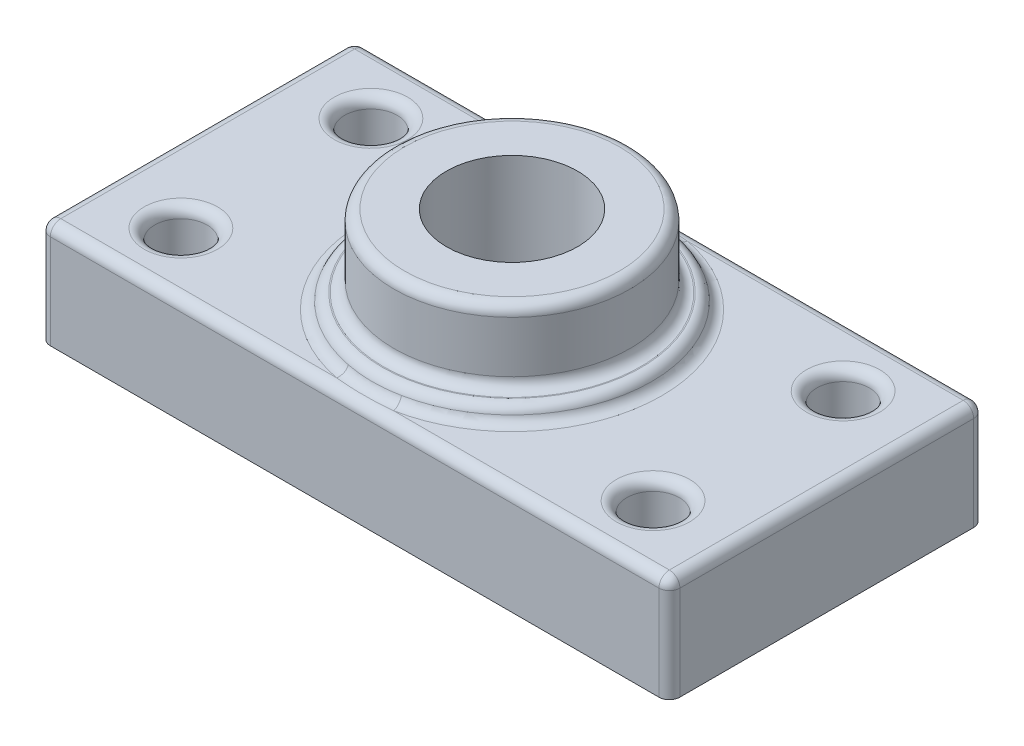
from build123d import *

# Parameters (mm, degrees)
SKETCH1_W               = 152.4
SKETCH1_H               = 76.2
SKETCH1_R               = 33.915986058
SKETCH1_R_2             = 6.35
BOSS_EXTRUDE4_DEPTH     = 25.4
SKETCH5_R               = 33.915986058
BOSS_EXTRUDE5_DEPTH     = 28.956
SKETCH6_R               = 28.575
BOSS_EXTRUDE6_DEPTH     = 46.482
SKETCH7_R               = 15.875
CUT_EXTRUDE2_DEPTH      = 51.054
CUT_EXTRUDE2_DEPTH_BACK = 0.254
SKETCH8_W               = 152.4
SKETCH8_H               = 76.2
BOSS_EXTRUDE8_DEPTH     = 2.54
FILLET1_R               = 2.54
FILLET2_R               = 2.54
FILLET3_R               = 2.54


with BuildPart() as part:
    # Sketch1 → Boss-Extrude4 (new body)
    with BuildSketch(Plane(origin=(0, 0, 0), x_dir=(1, 0, 0), z_dir=(0, 1, 0))):
        Rectangle(SKETCH1_W, SKETCH1_H)
        Circle(SKETCH1_R, mode=Mode.SUBTRACT)
        with Locations((57.15, -23.003511002)):
            Circle(SKETCH1_R_2, mode=Mode.SUBTRACT)
        with Locations((-57.15, -23.003511002)):
            Circle(SKETCH1_R_2, mode=Mode.SUBTRACT)
        with Locations((-57.15, 23.003511002)):
            Circle(SKETCH1_R_2, mode=Mode.SUBTRACT)
        with Locations((57.15, 23.003511002)):
            Circle(SKETCH1_R_2, mode=Mode.SUBTRACT)
    extrude(amount=BOSS_EXTRUDE4_DEPTH)

    # Sketch5 → Boss-Extrude5 (add)
    with BuildSketch(Plane(origin=(0, 0, 0), x_dir=(1, 0, 0), z_dir=(0, 1, 0))):
        Circle(SKETCH5_R)
    extrude(amount=BOSS_EXTRUDE5_DEPTH)

    # Sketch6 → Boss-Extrude6 (add)
    with BuildSketch(Plane(origin=(0, 0, 0), x_dir=(1, 0, 0), z_dir=(0, 1, 0))):
        Circle(SKETCH6_R)
    extrude(amount=BOSS_EXTRUDE6_DEPTH)

    # Sketch7 → Cut-Extrude2 (cut, two sides)
    with BuildSketch(Plane(origin=(0, 0, 0), x_dir=(1, 0, 0), z_dir=(0, 1, 0))) as cut_extrude2_sk:
        Circle(SKETCH7_R)
    extrude(amount=CUT_EXTRUDE2_DEPTH, mode=Mode.SUBTRACT)
    extrude(cut_extrude2_sk.sketch, amount=-CUT_EXTRUDE2_DEPTH_BACK, mode=Mode.SUBTRACT)

    # Sketch8 → Boss-Extrude8 (add)
    with BuildSketch(Plane(origin=(0, 0, 0), x_dir=(1, 0, 0), z_dir=(0, 1, 0))):
        Rectangle(SKETCH8_W, SKETCH8_H)
    extrude(amount=BOSS_EXTRUDE8_DEPTH)

    # Fillet1
    fillet1_edges = [part.edges().sort_by_distance(p)[0] for p in [
        (76.2, 12.7, 38.1),
        (-76.2, 12.7, 38.1),
        (-76.2, 12.7, -38.1),
        (76.2, 12.7, -38.1),
        (-33.915986058, 28.956, 0),
        (-28.575, 28.956, 0),
        (-28.575, 46.482, 0),
    ]]
    fillet(fillet1_edges, radius=FILLET1_R)

    # Fillet2
    fillet2_edges = [part.edges().sort_by_distance(p)[0] for p in [
        (76.2, 25.4, 0),
        (0, 25.4, 38.1),
        (0, 25.4, -38.1),
        (-76.2, 25.4, 0),
        (75.456051224, 25.4, -37.356051224),
        (-75.456051224, 25.4, -37.356051224),
        (-75.456051224, 25.4, 37.356051224),
        (75.456051224, 25.4, 37.356051224),
    ]]
    fillet(fillet2_edges, radius=FILLET2_R)

    # Fillet3
    fillet3_edges = [part.edges().sort_by_distance(p)[0] for p in [
        (50.8, 25.4, -23.003511002),
        (-63.5, 25.4, -23.003511002),
        (-63.5, 25.4, 23.003511002),
        (50.8, 25.4, 23.003511002),
        (-33.915986058, 25.4, 0),
    ]]
    fillet(fillet3_edges, radius=FILLET3_R)


solid = part.part
